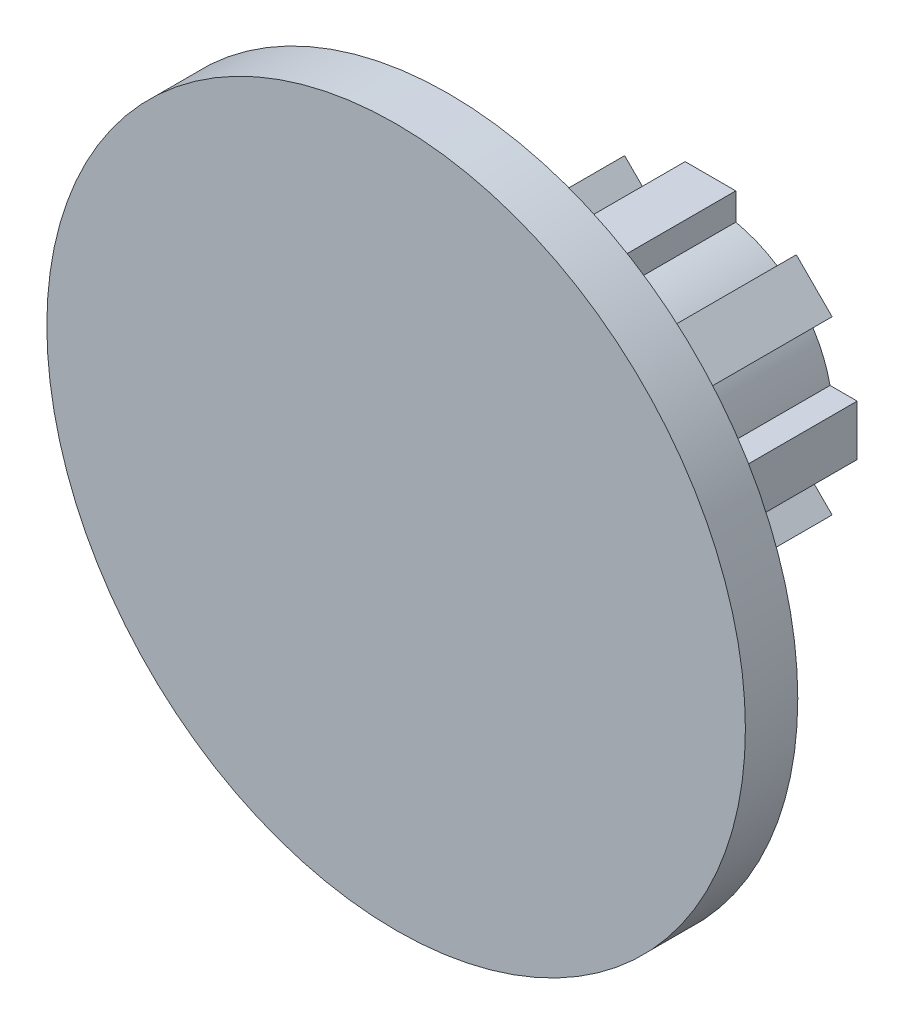
from build123d import *

# Parameters (mm, degrees)
BOSS_EXTRUDE1_DEPTH = 30
SKETCH2_R           = 5
CUT_EXTRUDE1_DEPTH  = 6
SKETCH3_R           = 40
BOSS_EXTRUDE2_DEPTH = 6


with BuildPart() as part:
    # Sketch1 → Boss-Extrude1 (new body)
    with BuildSketch(Plane.XY):
        with BuildLine():
            Line((-2.9, 13.696349879), (-2.9, 16.8))
            Line((-2.9, 16.8), (2.9, 16.8))
            Line((2.9, 16.8), (2.9, 13.696349879))
            ThreePointArc((2.9, 13.696349879), (5.357568053, 12.934313455), (7.634172211, 11.735391542))
            Line((7.634172211, 11.735391542), (9.828784258, 13.930003589))
            Line((9.828784258, 13.930003589), (13.930003589, 9.828784258))
            Line((13.930003589, 9.828784258), (11.735391542, 7.634172211))
            ThreePointArc((11.735391542, 7.634172211), (12.934313455, 5.357568053), (13.696349879, 2.9))
            Line((13.696349879, 2.9), (16.8, 2.9))
            Line((16.8, 2.9), (16.8, -2.9))
            Line((16.8, -2.9), (13.696349879, -2.9))
            ThreePointArc((13.696349879, -2.9), (12.934313455, -5.357568053), (11.735391542, -7.634172211))
            Line((11.735391542, -7.634172211), (13.930003589, -9.828784258))
            Line((13.930003589, -9.828784258), (9.828784258, -13.930003589))
            Line((9.828784258, -13.930003589), (7.634172211, -11.735391542))
            ThreePointArc((7.634172211, -11.735391542), (5.357568053, -12.934313455), (2.9, -13.696349879))
            Line((2.9, -13.696349879), (2.9, -16.8))
            Line((2.9, -16.8), (-2.9, -16.8))
            Line((-2.9, -16.8), (-2.9, -13.696349879))
            ThreePointArc((-2.9, -13.696349879), (-5.357568053, -12.934313455), (-7.634172211, -11.735391542))
            Line((-7.634172211, -11.735391542), (-9.828784258, -13.930003589))
            Line((-9.828784258, -13.930003589), (-13.930003589, -9.828784258))
            Line((-13.930003589, -9.828784258), (-11.735391542, -7.634172211))
            ThreePointArc((-11.735391542, -7.634172211), (-12.934313455, -5.357568053), (-13.696349879, -2.9))
            Line((-13.696349879, -2.9), (-16.8, -2.9))
            Line((-16.8, -2.9), (-16.8, 2.9))
            Line((-16.8, 2.9), (-13.696349879, 2.9))
            ThreePointArc((-13.696349879, 2.9), (-12.934313455, 5.357568053), (-11.735391542, 7.634172211))
            Line((-11.735391542, 7.634172211), (-13.930003589, 9.828784258))
            Line((-13.930003589, 9.828784258), (-9.828784258, 13.930003589))
            Line((-9.828784258, 13.930003589), (-7.634172211, 11.735391542))
            ThreePointArc((-7.634172211, 11.735391542), (-5.357568053, 12.934313455), (-2.9, 13.696349879))
        make_face()
    extrude(amount=BOSS_EXTRUDE1_DEPTH)

    # Sketch2 → Cut-Extrude1 (cut)
    with BuildSketch(Plane(origin=(0, 0, 0), x_dir=(-1, 0, 0), z_dir=(0, 0, -1))):
        Circle(SKETCH2_R)
    extrude(amount=-CUT_EXTRUDE1_DEPTH, mode=Mode.SUBTRACT)

    # Sketch3 → Boss-Extrude2 (add)
    with BuildSketch(Plane.XY.offset(30)):
        Circle(SKETCH3_R)
    extrude(amount=BOSS_EXTRUDE2_DEPTH)


solid = part.part
